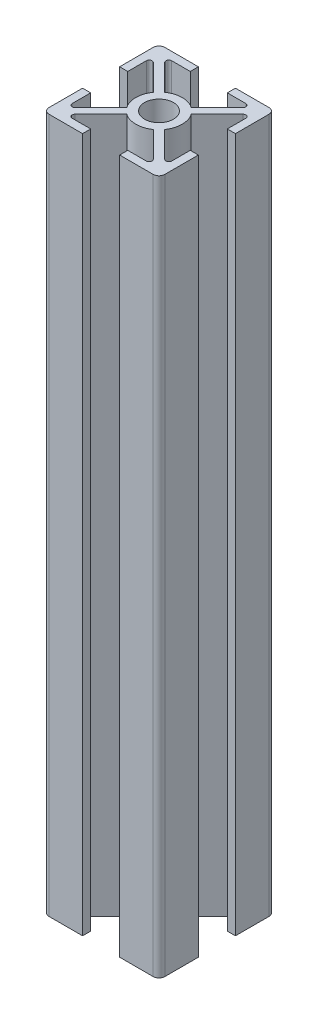
from build123d import *

# Parameters (mm, degrees)
SKETCH1_R           = 2.5
BOSS_EXTRUDE1_DEPTH = 120
FILLET1_R           = 0.5
FILLET2_R           = 1


with BuildPart() as part:
    # Sketch1 → Boss-Extrude1 (new body)
    with BuildSketch(Plane(origin=(0, 0, 0), x_dir=(1, 0, 0), z_dir=(0, 1, 0))):
        with BuildLine():
            Line((3.2, 10), (3.2, 8.6))
            Line((3.2, 8.6), (7.610050506, 8.6))
            Line((7.610050506, 8.6), (2.289805316, 3.27975481))
            ThreePointArc((2.289805316, 3.27975481), (0, 4), (-2.289805316, 3.27975481))
            Line((-2.289805316, 3.27975481), (-7.610050506, 8.6))
            Line((-7.610050506, 8.6), (-3.2, 8.6))
            Line((-3.2, 8.6), (-3.2, 10))
            Line((-3.2, 10), (-10, 10))
            Line((-10, 10), (-10, 3.2))
            Line((-10, 3.2), (-8.6, 3.2))
            Line((-8.6, 3.2), (-8.6, 7.610050506))
            Line((-8.6, 7.610050506), (-3.27975481, 2.289805316))
            ThreePointArc((-3.27975481, 2.289805316), (-4, 0), (-3.27975481, -2.289805316))
            Line((-3.27975481, -2.289805316), (-8.6, -7.610050506))
            Line((-8.6, -7.610050506), (-8.6, -3.2))
            Line((-8.6, -3.2), (-10, -3.2))
            Line((-10, -3.2), (-10, -10))
            Line((-10, -10), (-3.2, -10))
            Line((-3.2, -10), (-3.2, -8.6))
            Line((-3.2, -8.6), (-7.610050506, -8.6))
            Line((-7.610050506, -8.6), (-2.289805316, -3.27975481))
            ThreePointArc((-2.289805316, -3.27975481), (0, -4), (2.289805316, -3.27975481))
            Line((2.289805316, -3.27975481), (7.610050506, -8.6))
            Line((7.610050506, -8.6), (3.2, -8.6))
            Line((3.2, -8.6), (3.2, -10))
            Line((3.2, -10), (10, -10))
            Line((10, -10), (10, -3.2))
            Line((10, -3.2), (8.6, -3.2))
            Line((8.6, -3.2), (8.6, -7.610050506))
            Line((8.6, -7.610050506), (3.27975481, -2.289805316))
            ThreePointArc((3.27975481, -2.289805316), (4, 0), (3.27975481, 2.289805316))
            Line((3.27975481, 2.289805316), (8.6, 7.610050506))
            Line((8.6, 7.610050506), (8.6, 3.2))
            Line((8.6, 3.2), (10, 3.2))
            Line((10, 3.2), (10, 10))
            Line((10, 10), (3.2, 10))
        make_face()
        Circle(SKETCH1_R, mode=Mode.SUBTRACT)
    extrude(amount=BOSS_EXTRUDE1_DEPTH)

    # Fillet1
    fillet1_edges = [part.edges().sort_by_distance(p)[0] for p in [
        (8.6, 60, -7.610050506),
        (8.6, 60, 7.610050506),
        (7.610050506, 60, 8.6),
        (-7.610050506, 60, 8.6),
        (-8.6, 60, 7.610050506),
        (-8.6, 60, -7.610050506),
        (-7.610050506, 60, -8.6),
        (7.610050506, 60, -8.6),
    ]]
    fillet(fillet1_edges, radius=FILLET1_R)

    # Fillet2
    fillet2_edges = [part.edges().sort_by_distance(p)[0] for p in [
        (10, 60, 10),
        (-10, 60, 10),
        (-10, 60, -10),
        (10, 60, -10),
    ]]
    fillet(fillet2_edges, radius=FILLET2_R)


solid = part.part
